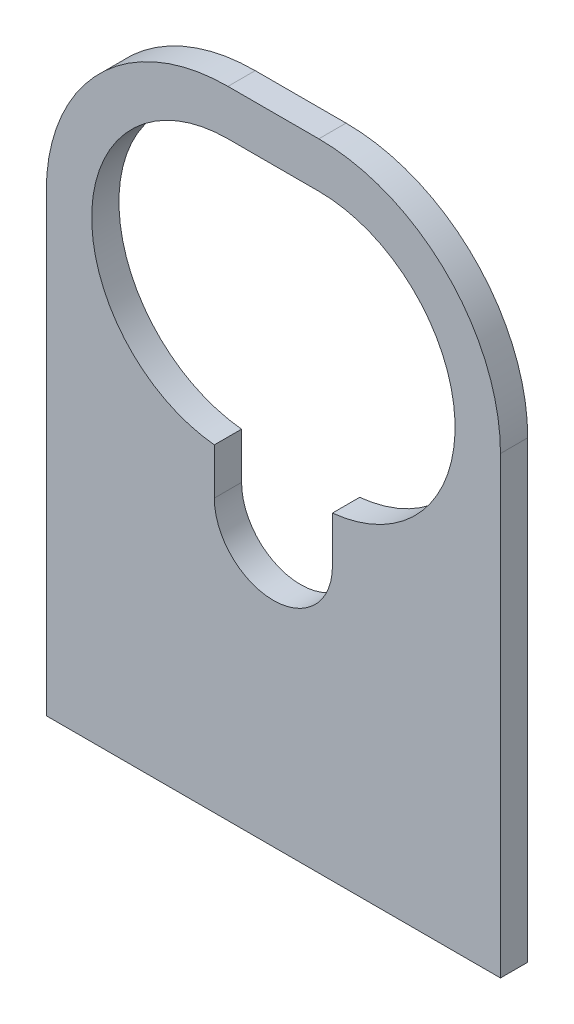
from build123d import *

# Parameters (mm, degrees)
SKETCH1_W               = 50
SKETCH1_H               = 70
BOSS_EXTRUDE1_DEPTH     = 3
SKETCH2_R               = 6.5
CUT_EXTRUDE1_DEPTH      = 1
CUT_EXTRUDE1_DEPTH_BACK = 4
CUT_EXTRUDE2_DEPTH      = 1
CUT_EXTRUDE2_DEPTH_BACK = 4
SKETCH4_W               = 13
SKETCH4_H               = 15
CUT_EXTRUDE3_DEPTH      = 1
CUT_EXTRUDE3_DEPTH_BACK = 4
FILLET1_R               = 20


with BuildPart() as part:
    # Sketch1 → Boss-Extrude1 (new body)
    with BuildSketch(Plane.XY):
        with Locations((0, 5)):
            Rectangle(SKETCH1_W, SKETCH1_H)
    extrude(amount=BOSS_EXTRUDE1_DEPTH)

    # Sketch2 → Cut-Extrude1 (cut, two sides)
    with BuildSketch(Plane.XY.offset(3)) as cut_extrude1_sk:
        Circle(SKETCH2_R)
    extrude(amount=CUT_EXTRUDE1_DEPTH, mode=Mode.SUBTRACT)
    extrude(cut_extrude1_sk.sketch, amount=-CUT_EXTRUDE1_DEPTH_BACK, mode=Mode.SUBTRACT)

    # Sketch3 → Cut-Extrude2 (cut, two sides)
    with BuildSketch(Plane.XY.offset(3)) as cut_extrude2_sk:
        with BuildLine():
            Line((-5, 35), (5, 35))
            ThreePointArc((5, 35), (20, 20), (5, 5))
            Line((5, 5), (-5, 5))
            ThreePointArc((-5, 5), (-20, 20), (-5, 35))
        make_face()
    extrude(amount=CUT_EXTRUDE2_DEPTH, mode=Mode.SUBTRACT)
    extrude(cut_extrude2_sk.sketch, amount=-CUT_EXTRUDE2_DEPTH_BACK, mode=Mode.SUBTRACT)

    # Sketch4 → Cut-Extrude3 (cut, two sides)
    with BuildSketch(Plane.XY.offset(3)) as cut_extrude3_sk:
        with Locations((0, 7.5)):
            Rectangle(SKETCH4_W, SKETCH4_H)
    extrude(amount=CUT_EXTRUDE3_DEPTH, mode=Mode.SUBTRACT)
    extrude(cut_extrude3_sk.sketch, amount=-CUT_EXTRUDE3_DEPTH_BACK, mode=Mode.SUBTRACT)

    # Fillet1
    fillet1_edges = [part.edges().sort_by_distance(p)[0] for p in [
        (-25, 40, 1.5),
        (25, 40, 1.5),
    ]]
    fillet(fillet1_edges, radius=FILLET1_R)


solid = part.part
